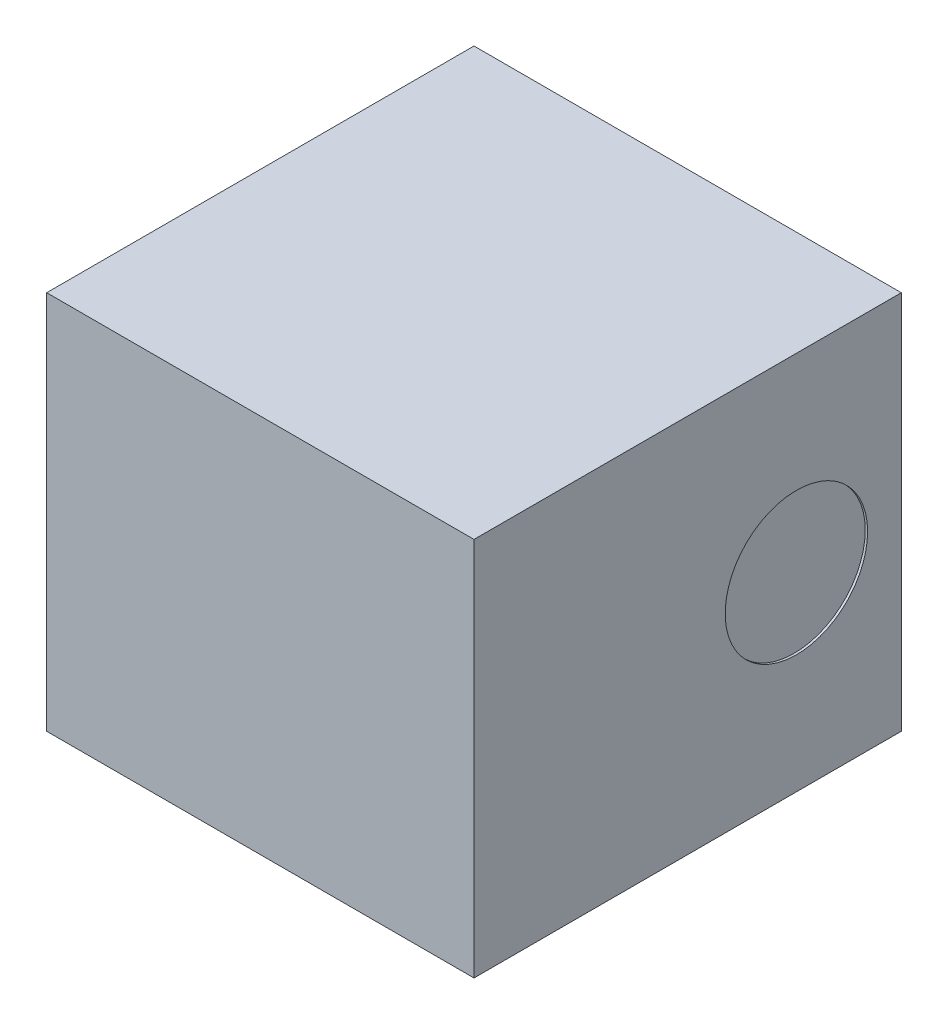
from build123d import *

# Parameters (mm, degrees)
SKETCH1_W           = 0.9
SKETCH1_H           = 0.9
BOSS_EXTRUDE1_DEPTH = 0.8
SKETCH2_R           = 0.15
CUT_EXTRUDE1_DEPTH  = 0.005


with BuildPart() as part:
    # Sketch1 → Boss-Extrude1 (new body)
    with BuildSketch(Plane(origin=(0, 0, 0), x_dir=(1, 0, 0), z_dir=(0, 1, 0))):
        Rectangle(SKETCH1_W, SKETCH1_H)
    extrude(amount=BOSS_EXTRUDE1_DEPTH)

    # Sketch2 → Cut-Extrude1 (cut)
    with BuildSketch(Plane(origin=(0.45, 0, 0), x_dir=(0, 0, -1), z_dir=(1, 0, 0))):
        with Locations((0.229047371, 0.4)):
            Circle(SKETCH2_R)
    extrude(amount=-CUT_EXTRUDE1_DEPTH, mode=Mode.SUBTRACT)


solid = part.part
